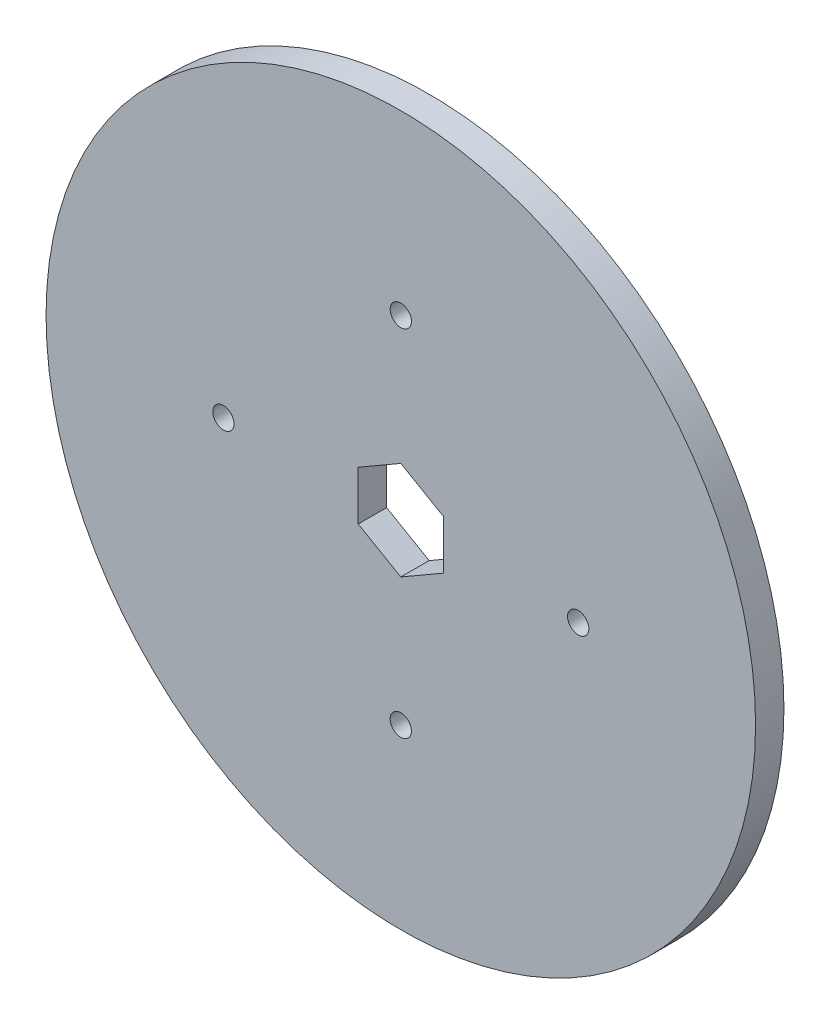
from build123d import *

# Parameters (mm, degrees)
SKETCH1_R           = 50
BOSS_EXTRUDE1_DEPTH = 4
CUT_EXTRUDE1_DEPTH  = 12
SKETCH5_R           = 1.5
CUT_EXTRUDE2_DEPTH  = 4


with BuildPart() as part:
    # Sketch1 → Boss-Extrude1 (new body)
    with BuildSketch(Plane.XY):
        with Locations((-42.286719292, 29.938997259)):
            Circle(SKETCH1_R)
    extrude(amount=BOSS_EXTRUDE1_DEPTH)

    # Sketch4 → Cut-Extrude1 (cut)
    with BuildSketch(Plane.XY.offset(4)):
        Polygon((-42.286719292, 23.010794029), (-36.286719292, 26.474895644), (-36.286719292, 33.403098874), (-42.286719292, 36.867200489), (-48.286719292, 33.403098874), (-48.286719292, 26.474895644), align=None)
    extrude(amount=-CUT_EXTRUDE1_DEPTH, mode=Mode.SUBTRACT)

    # Sketch5 → Cut-Extrude2 (cut)
    with BuildSketch(Plane.XY.offset(4)):
        with Locations((-67.286719292, 29.938997259)):
            Circle(SKETCH5_R)
        with Locations((-42.286719292, 54.938997259)):
            Circle(SKETCH5_R)
        with Locations((-17.286719292, 29.938997259)):
            Circle(SKETCH5_R)
        with Locations((-42.286719292, 4.938997259)):
            Circle(SKETCH5_R)
    extrude(amount=-CUT_EXTRUDE2_DEPTH, mode=Mode.SUBTRACT)


solid = part.part
